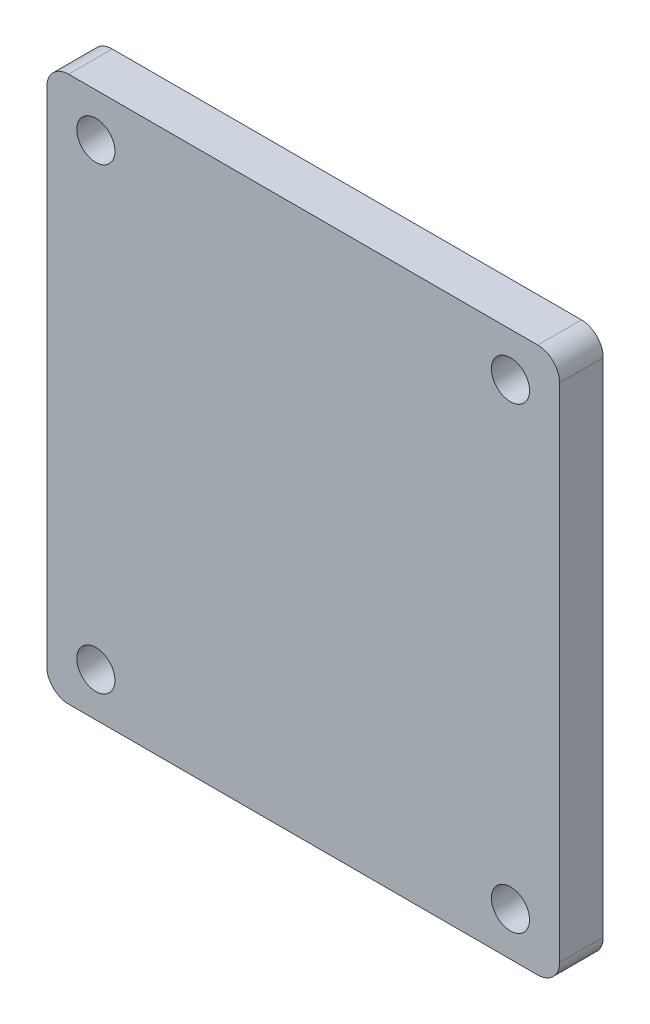
from build123d import *

# Parameters (mm, degrees)
SKETCH_1_W                  = 47
SKETCH_1_H                  = 50
EXTRUDE_1_DEPTH             = 4
HOLE_WIZARD_3_5_3_5_1_D     = 3.5
HOLE_WIZARD_3_5_3_5_1_DEPTH = 4
FILLET_1_R                  = 2


with BuildPart() as part:
    # 草图1 → 凸台-拉伸1 (new body)
    with BuildSketch(Plane.XY):
        Rectangle(SKETCH_1_W, SKETCH_1_H)
    extrude(amount=EXTRUDE_1_DEPTH)

    # Ø3.5 (3.5) 直径孔1
    with Locations(Plane.XY.offset(4)):
        with Locations((-19, 21), (19, 21), (-19, -21), (19, -21)):
            Hole(HOLE_WIZARD_3_5_3_5_1_D / 2, depth=HOLE_WIZARD_3_5_3_5_1_DEPTH)

    # 圆角1
    fillet_1_edges = [part.edges().sort_by_distance(p)[0] for p in [
        (23.5, -25, 2),
        (-23.5, -25, 2),
        (-23.5, 25, 2),
        (23.5, 25, 2),
    ]]
    fillet(fillet_1_edges, radius=FILLET_1_R)


solid = part.part
